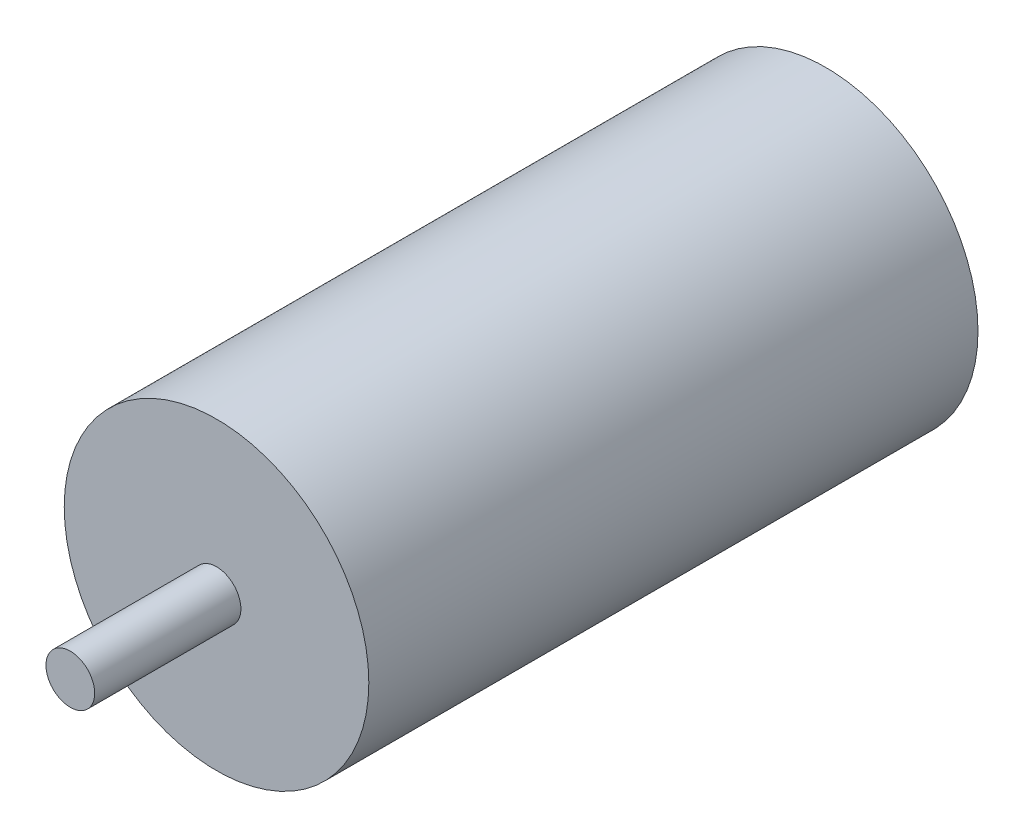
from build123d import *

# Parameters (mm, degrees)
SKETCH1_R           = 12.5
BOSS_EXTRUDE1_DEPTH = 50
SKETCH2_R           = 2
BOSS_EXTRUDE2_DEPTH = 12


with BuildPart() as part:
    # Sketch1 → Boss-Extrude1 (new body)
    with BuildSketch(Plane.XY):
        Circle(SKETCH1_R)
    extrude(amount=BOSS_EXTRUDE1_DEPTH)

    # Sketch2 → Boss-Extrude2 (add)
    with BuildSketch(Plane.XY.offset(50)):
        Circle(SKETCH2_R)
    extrude(amount=BOSS_EXTRUDE2_DEPTH)


solid = part.part
